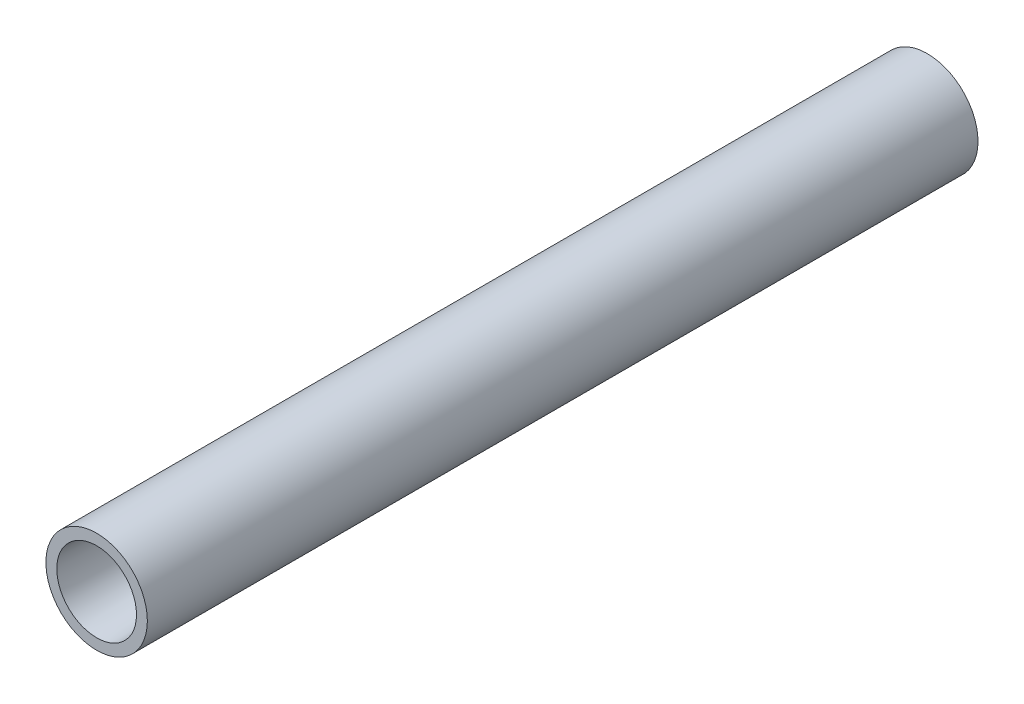
from build123d import *

# Parameters (mm, degrees)
SKETCH1_R           = 4
BOSS_EXTRUDE1_DEPTH = 65.5
SKETCH2_R           = 1
CUT_EXTRUDE1_DEPTH  = 66.5
SKETCH3_R           = 3.14325
CUT_EXTRUDE2_DEPTH  = 9.0297
CUT_EXTRUDE2_TAPER  = 2.328
SKETCH4_R           = 3.14325
CUT_EXTRUDE3_DEPTH  = 9.0297
CUT_EXTRUDE3_TAPER  = 2.328


with BuildPart() as part:
    # Sketch1 → Boss-Extrude1 (new body)
    with BuildSketch(Plane.XY):
        Circle(SKETCH1_R)
    extrude(amount=BOSS_EXTRUDE1_DEPTH)

    # Sketch2 → Cut-Extrude1 (cut, through all)
    with BuildSketch(Plane.XY):
        Circle(SKETCH2_R)
    extrude(amount=CUT_EXTRUDE1_DEPTH, mode=Mode.SUBTRACT)

    # Sketch3 → Cut-Extrude2 (cut)
    with BuildSketch(Plane.XY):
        Circle(SKETCH3_R)
    extrude(amount=CUT_EXTRUDE2_DEPTH, taper=CUT_EXTRUDE2_TAPER, mode=Mode.SUBTRACT)

    # Sketch4 → Cut-Extrude3 (cut)
    with BuildSketch(Plane.XY.offset(65.5)):
        Circle(SKETCH4_R)
    extrude(amount=-CUT_EXTRUDE3_DEPTH, taper=CUT_EXTRUDE3_TAPER, mode=Mode.SUBTRACT)


solid = part.part
